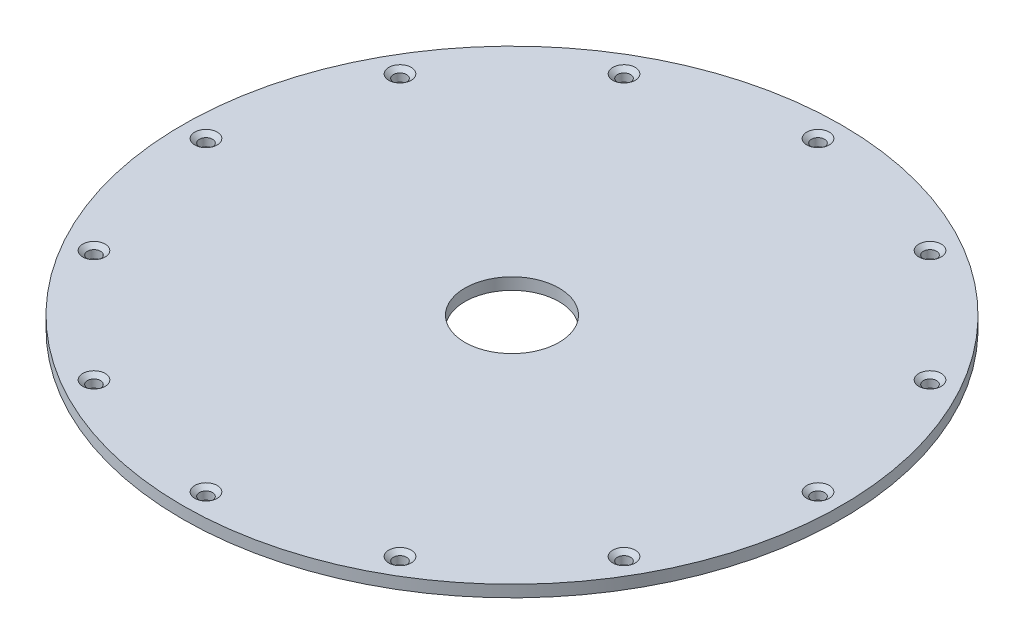
from build123d import *

# Parameters (mm, degrees)
SKETCH1_W                                         = 38.1
SKETCH1_H                                         = 1.5875
CSK_FOR_0_FLAT_HEAD_MACHINE_SCREW_100_D           = 1.778
CSK_FOR_0_FLAT_HEAD_MACHINE_SCREW_100_CSINK_D     = 3.0226
CSK_FOR_0_FLAT_HEAD_MACHINE_SCREW_100_CSINK_ANGLE = 100
CIRPATTERN1_COUNT                                 = 12


with BuildPart() as part:
    # Sketch1 → Revolve1 (revolve)
    with BuildSketch(Plane.XY):
        with Locations((-25.4, 0.79375)):
            Rectangle(SKETCH1_W, SKETCH1_H)
    revolve(axis=Axis((0, 55, 0), (0, -1, 0)))

    # CSK for #0 Flat Head Machine Screw (100)1 (through all)
    with Locations(Plane(origin=(0, 1.5875, 0), x_dir=(1, 0, 0), z_dir=(0, 1, 0))):
        with Locations((-41.275, 0)):
            csk_for_0_flat_head_machine_screw_100 = CounterSinkHole(CSK_FOR_0_FLAT_HEAD_MACHINE_SCREW_100_D / 2, CSK_FOR_0_FLAT_HEAD_MACHINE_SCREW_100_CSINK_D / 2, counter_sink_angle=CSK_FOR_0_FLAT_HEAD_MACHINE_SCREW_100_CSINK_ANGLE)

    # CirPattern1: CSK for #0 Flat Head Machine Screw (100)1 ×12 about axis
    cirpattern1_axis = Axis((0, 0, 0), (0, 1, 0))
    for i in range(1, CIRPATTERN1_COUNT):
        add(csk_for_0_flat_head_machine_screw_100.rotate(cirpattern1_axis, i * 360 / CIRPATTERN1_COUNT), mode=Mode.SUBTRACT)


solid = part.part
